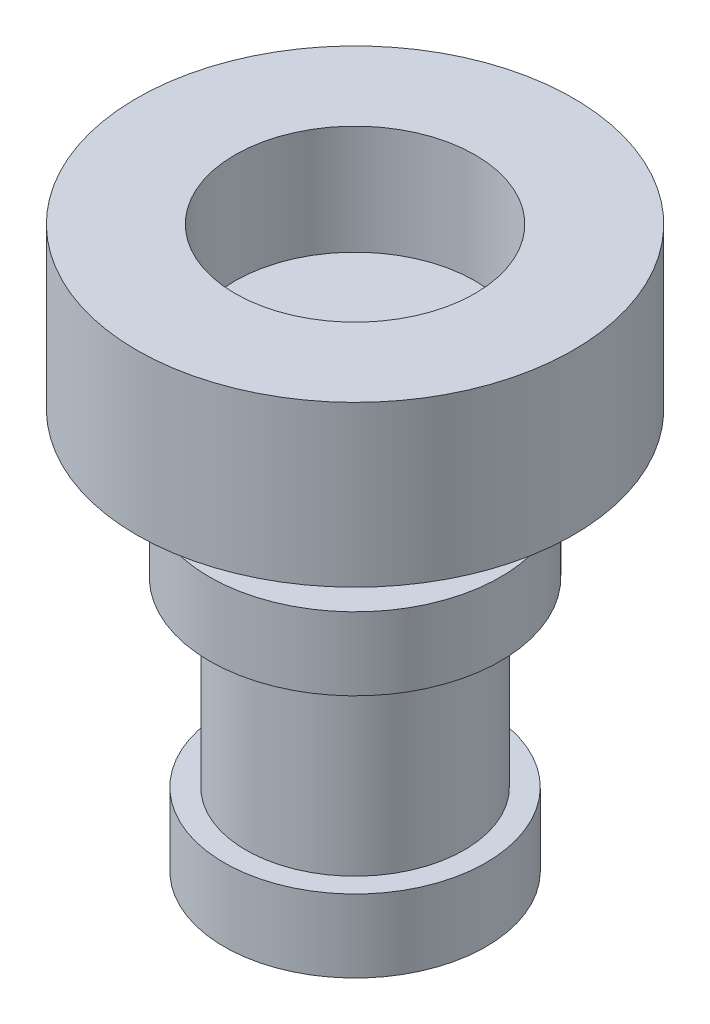
from build123d import *

# Parameters (mm, degrees)
SKETCH1_R           = 3
BOSS_EXTRUDE1_DEPTH = 2.2
SKETCH1_3_R         = 1.6
BOSS_EXTRUDE2_DEPTH = 1
SKETCH5_R           = 1.5
BOSS_EXTRUDE3_DEPTH = 1
SKETCH6_R           = 2
BOSS_EXTRUDE4_DEPTH = 1
SKETCH8_R           = 1.5
BOSS_EXTRUDE5_DEPTH = 3.5
SKETCH10_R          = 1.8
BOSS_EXTRUDE6_DEPTH = 1
SKETCH12_R          = 1.65
CUT_EXTRUDE1_DEPTH  = 1.5


with BuildPart() as part:
    # Sketch1 → Boss-Extrude1 (new body)
    with BuildSketch(Plane(origin=(0, 0, 0), x_dir=(1, 0, 0), z_dir=(0, 1, 0))):
        with Locations((-0.522013312, 0.511138034)):
            Circle(SKETCH1_R)
    extrude(amount=BOSS_EXTRUDE1_DEPTH)

    # Sketch1_3 → Boss-Extrude2 (add)
    with BuildSketch(Plane(origin=(0, 0, 0), x_dir=(1, 0, 0), z_dir=(0, 1, 0))):
        with Locations((-0.522013312, 0.511138034)):
            Circle(SKETCH1_3_R)
    extrude(amount=BOSS_EXTRUDE2_DEPTH)

    # Sketch5 → Boss-Extrude3 (add)
    with BuildSketch(Plane.XZ):
        with Locations((-0.522013312, -0.511138034)):
            Circle(SKETCH5_R)
    extrude(amount=BOSS_EXTRUDE3_DEPTH)

    # Sketch6 → Boss-Extrude4 (add)
    with BuildSketch(Plane.XZ.offset(1)):
        with Locations((-0.522013312, -0.511138034)):
            Circle(SKETCH6_R)
    extrude(amount=BOSS_EXTRUDE4_DEPTH)

    # Sketch8 → Boss-Extrude5 (add)
    with BuildSketch(Plane(origin=(0, -2, 0), x_dir=(-1, 0, 0), z_dir=(0, -1, 0))):
        with Locations((0.522013312, 0.511138034)):
            Circle(SKETCH8_R)
    extrude(amount=BOSS_EXTRUDE5_DEPTH)

    # Sketch10 → Boss-Extrude6 (add)
    with BuildSketch(Plane.XZ.offset(5.5)):
        with Locations((-0.522013312, -0.511138034)):
            Circle(SKETCH10_R)
    extrude(amount=-BOSS_EXTRUDE6_DEPTH)

    # Sketch12 → Cut-Extrude1 (cut)
    with BuildSketch(Plane(origin=(0, 2.2, 0), x_dir=(1, 0, 0), z_dir=(0, 1, 0))):
        with Locations((-0.522013312, 0.511138034)):
            Circle(SKETCH12_R)
    extrude(amount=-CUT_EXTRUDE1_DEPTH, mode=Mode.SUBTRACT)


solid = part.part
